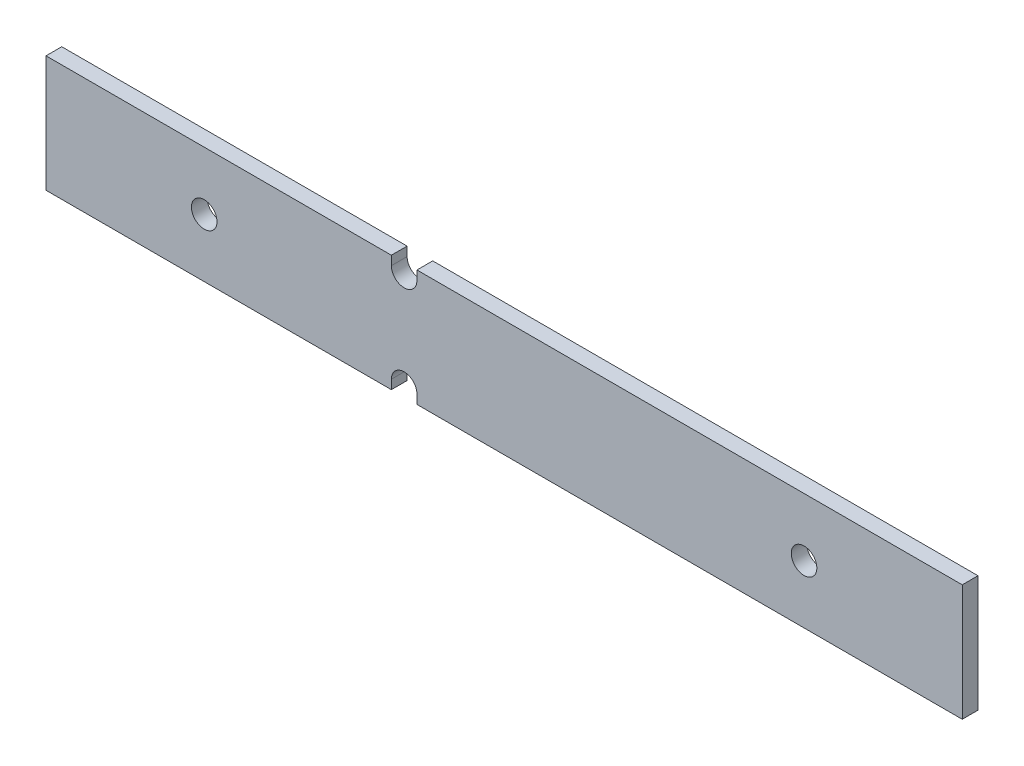
from build123d import *

# Parameters (mm, degrees)
SKETCH1_W                  = 93.116399905
SKETCH1_H                  = 11.836399908
BOSS_EXTRUDE1_DEPTH        = 1.6002
F_2_6_2_6_DIAMETER_HOLE1_D = 2.6
SKETCH6_W                  = 2.6
SKETCH6_H                  = 0.920741122
CUT_EXTRUDE1_DEPTH         = 2.6002


with BuildPart() as part:
    # Sketch1 → Boss-Extrude1 (new body)
    with BuildSketch(Plane.XY.offset(1.63)):
        with Locations((-40.639999999, 0)):
            Rectangle(SKETCH1_W, SKETCH1_H)
    extrude(amount=BOSS_EXTRUDE1_DEPTH)

    # Ø2.6 (2.6) Diameter Hole1 (through all)
    with Locations(Plane.XY.offset(3.2302)):
        with Locations((-50.800000064, 4.997458832), (-50.800000064, -4.997458832), (-10.160000092, -7.6e-08), (-71.119999812, -3.5e-08)):
            Hole(F_2_6_2_6_DIAMETER_HOLE1_D / 2)

    # Sketch6 → Cut-Extrude1 (cut, through all)
    with BuildSketch(Plane.XY.offset(3.2302)):
        with Locations((-50.800000064, 5.457829393)):
            Rectangle(SKETCH6_W, SKETCH6_H)
        with Locations((-50.800000064, -5.457829393)):
            Rectangle(SKETCH6_W, SKETCH6_H)
    extrude(amount=-CUT_EXTRUDE1_DEPTH, mode=Mode.SUBTRACT)


solid = part.part
